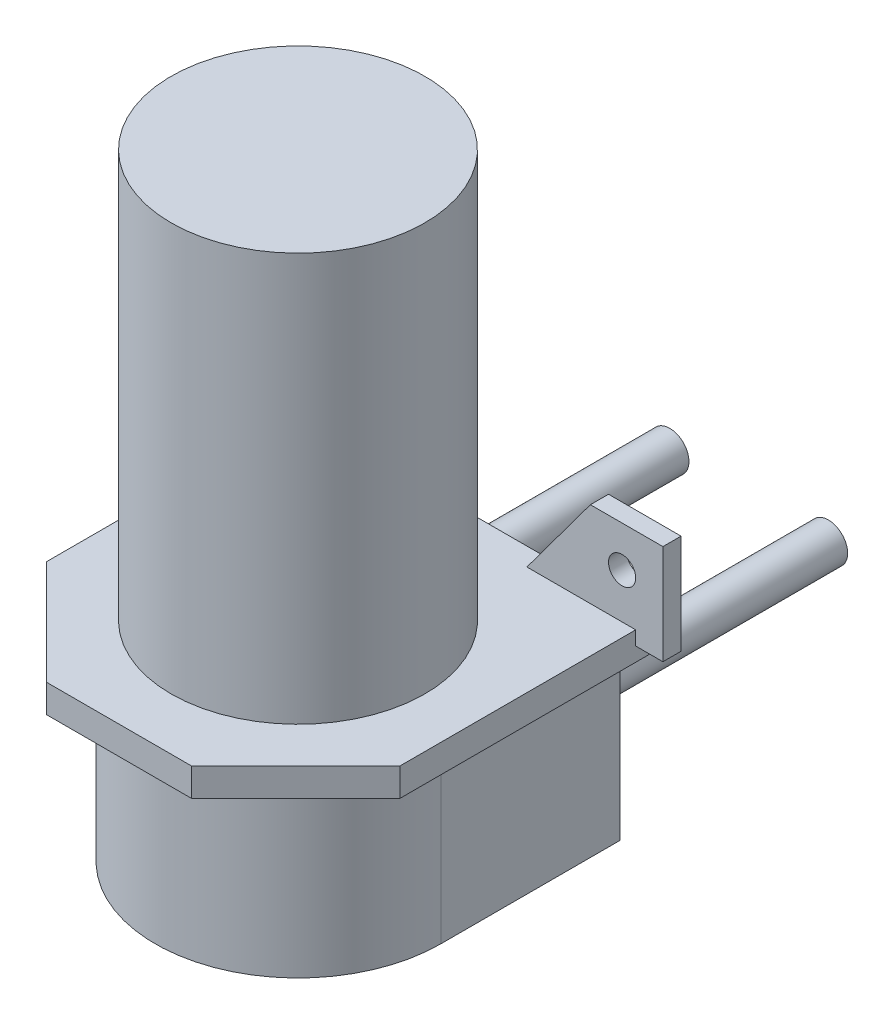
from build123d import *

# Parameters (mm, degrees)
SKETCH1_R             = 14
BOSS_EXTRUDE1_DEPTH   = 45
BOSS_EXTRUDE3_DEPTH   = 3.1
SKETCH4_R             = 15.75
BOSS_EXTRUDE4_DEPTH   = 23
SKETCH5_W             = 31.5
SKETCH5_H             = 19.75
BOSS_EXTRUDE5_DEPTH   = 19.9
SKETCH6_R             = 2.125
CUT_EXTRUDE1_DEPTH    = 19.6
SKETCH7_R             = 1.5
BOSS_EXTRUDE6_DEPTH   = 2
SKETCH6_2_R           = 2.125
BOSS_EXTRUDE7_DEPTH   = 30
BOSS_EXTRUDE7_2_DEPTH = 30


with BuildPart() as part:
    # Sketch1 → Boss-Extrude1 (new body)
    with BuildSketch(Plane(origin=(0, 0, 0), x_dir=(1, 0, 0), z_dir=(0, 1, 0))):
        Circle(SKETCH1_R)
    extrude(amount=BOSS_EXTRUDE1_DEPTH)

    # Sketch3 → Boss-Extrude3 (add)
    with BuildSketch(Plane.XZ):
        Polygon((-8, 19.75), (-19.5, 8.25), (-19.5, -19.75), (19.5, -19.75), (19.5, 8.25), (8, 19.75), align=None)
    extrude(amount=BOSS_EXTRUDE3_DEPTH)

    # Sketch4 → Boss-Extrude4 (add)
    with BuildSketch(Plane(origin=(0, 0, 0), x_dir=(1, 0, 0), z_dir=(0, 1, 0))):
        Circle(SKETCH4_R)
    extrude(amount=-BOSS_EXTRUDE4_DEPTH)

    # Sketch5 → Boss-Extrude5 (add)
    with BuildSketch(Plane.XZ.offset(3.1)):
        with Locations((0, -9.875)):
            Rectangle(SKETCH5_W, SKETCH5_H)
    extrude(amount=BOSS_EXTRUDE5_DEPTH)

    # Sketch6 → Cut-Extrude1 (cut)
    with BuildSketch(Plane(origin=(0, 0, -19.75), x_dir=(-1, 0, 0), z_dir=(0, 0, -1))):
        with Locations((-8.75, -13)):
            Circle(SKETCH6_R)
        with Locations((8.75, -13)):
            Circle(SKETCH6_R)
    extrude(amount=-CUT_EXTRUDE1_DEPTH, mode=Mode.SUBTRACT)

    # Sketch7 → Boss-Extrude6 (add)
    with BuildSketch(Plane(origin=(0, 0, -19.75), x_dir=(-1, 0, 0), z_dir=(0, 0, -1))):
        Polygon((-22.5, -1.55), (-19.5, -1.55), (-19.5, 0), (-7.5, 0), (-14.5, 9.45), (-18, 9.45), (-22.5, 9.45), align=None)
        with Locations((-18, 4.95)):
            Circle(SKETCH7_R, mode=Mode.SUBTRACT)
        Polygon((14.5, 9.45), (7.5, 0), (19.5, 0), (19.5, -1.55), (22.5, -1.55), (22.5, 9.45), (18, 9.45), align=None)
        with Locations((18, 4.95)):
            Circle(SKETCH7_R, mode=Mode.SUBTRACT)
    extrude(amount=-BOSS_EXTRUDE6_DEPTH)


with BuildPart() as body_2:
    # Sketch6_2 → Boss-Extrude7 (new body)
    with BuildSketch(Plane(origin=(0, 0, -19.75), x_dir=(-1, 0, 0), z_dir=(0, 0, -1))):
        with Locations((-8.75, -13)):
            Circle(SKETCH6_2_R)
    extrude(amount=BOSS_EXTRUDE7_DEPTH)


with BuildPart() as body_3:
    # Sketch6_2 → Boss-Extrude7 2 (new body)
    with BuildSketch(Plane(origin=(0, 0, -19.75), x_dir=(-1, 0, 0), z_dir=(0, 0, -1))):
        with Locations((8.75, -13)):
            Circle(SKETCH6_2_R)
    extrude(amount=BOSS_EXTRUDE7_2_DEPTH)


solid = Compound([part.part, body_2.part, body_3.part])
